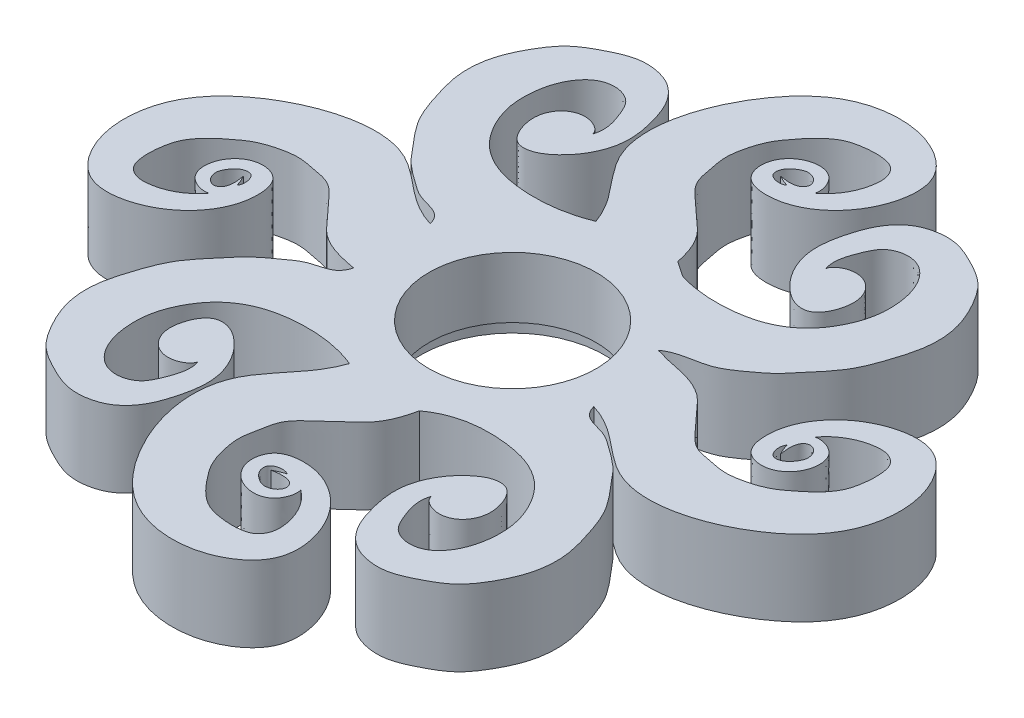
from build123d import *

# Parameters (mm, degrees)
BOSS_EXTRUDE2_DEPTH = 10
SKETCH2_R           = 13.166490973
BOSS_EXTRUDE4_DEPTH = 10
SKETCH4_R           = 10.996
CUT_EXTRUDE1_DEPTH  = 10
SKETCH5_R           = 12.126
CUT_EXTRUDE2_DEPTH  = 2


with BuildPart() as part:
    # Sketch1 → Boss-Extrude2 (new body)
    with BuildSketch(Plane(origin=(0, 0, 0), x_dir=(1, 0, 0), z_dir=(0, 1, 0))):
        with BuildLine():
            add(Edge.make_bspline(
                [(34.188363514, 44.956596514), (33.701598666, 43.048036253), (30.95739019, 43.115245722), (28.118998449, 40.970403917), (25.878188681, 39.331460779), (24.404677264, 37.426125449), (22.941084472, 35.794270593), (21.235407173, 33.479842018), (19.985078829, 30.008395243), (18.889058016, 26.247854831), (19.108830289, 22.745657785), (19.725757566, 20.92378151), (20.092106533, 20.092106533)],
                knots=[0, 0, 0, 0, 0.047266575, 0.084492057, 0.118112524, 0.141184856, 0.165634032, 0.192608699, 0.237940364, 0.289819658, 0.32418302, 0.354847276, 0.354847276, 0.354847276, 0.354847276], degree=3))
            Line((20.092106533, 20.092106533), (26.01328336, 26.01328336))
            add(Edge.make_bspline(
                [(26.01328336, 26.01328336), (26.052529787, 26.268426348), (26.278747771, 27.439968658), (27.14866517, 29.654095335), (29.108744684, 32.428855421), (31.966179785, 34.173665176), (33.996161891, 34.692283129), (34.836749566, 34.836749566)],
                knots=[0.460515809, 0.460515809, 0.460515809, 0.460515809, 0.478276136, 0.542635526, 0.623024021, 0.708168641, 0.766773984, 0.766773984, 0.766773984, 0.766773984], degree=3))
            Line((34.836749566, 34.836749566), (42.014455927, 42.014455927))
            add(Edge.make_bspline(
                [(34.188363514, 44.956596514), (34.412632763, 44.909046824), (35.135898032, 44.740206472), (36.778212553, 44.111022962), (39.947733796, 44.722787853), (41.031599473, 42.901571115), (42.014455927, 42.014455927)],
                knots=[0.810573593, 0.810573593, 0.810573593, 0.810573593, 0.822647339, 0.849801987, 0.902946428, 0.968114768, 0.968114768, 0.968114768, 0.968114768], degree=3))
        make_face()
        with BuildLine():
            Line((26.01328336, 26.01328336), (20.092106533, 20.092106533))
            add(Edge.make_bspline(
                [(20.092106533, 20.092106533), (20.391405304, 19.412646998), (21.173087456, 17.934573709), (22.855976348, 15.446940047), (25.899000157, 13.736428609), (29.019853456, 12.320498914), (31.692855633, 12.529433804), (34.075188007, 13.361697368), (36.025463952, 15.374095844), (37.304367596, 18.905964925), (38.234125799, 23.697087846), (36.050935714, 27.683689746), (33.885547102, 29.409321454), (32.695248955, 30.106562845), (30.959854801, 30.362175237), (29.737427553, 29.109049648), (29.167704554, 27.794524876), (28.848219551, 26.33981112), (29.051776005, 24.637379388), (29.977289897, 23.259457338), (31.684162076, 22.403328871), (33.422522957, 22.601417527), (34.534014203, 23.529934128), (34.637188493, 23.988642652), (34.646815974, 24.066379751)],
                knots=[0.354847276, 0.354847276, 0.354847276, 0.354847276, 0.379899275, 0.41085446, 0.455212464, 0.495953054, 0.524736546, 0.543496723, 0.580828475, 0.614309776, 0.670605327, 0.741152887, 0.752796809, 0.764260994, 0.788347673, 0.804360394, 0.819458631, 0.836969807, 0.854153952, 0.876412827, 0.889806592, 0.917326832, 0.931104592, 0.933826593, 0.933826593, 0.933826593, 0.933826593], degree=3))
            add(Edge.make_bspline(
                [(34.646815974, 24.066379751), (35.14201703, 22.640852122), (34.457931313, 20.557953149), (33.229845661, 17.848412965), (31.041923292, 16.974982467), (28.723356671, 17.471160138), (26.799485597, 19.52788522), (25.866296411, 22.561566295), (25.844067539, 24.913202835), (26.01328336, 26.01328336)],
                knots=[0, 0, 0, 0, 0.099619212, 0.145832416, 0.199041029, 0.246529323, 0.301572291, 0.383939961, 0.460515809, 0.460515809, 0.460515809, 0.460515809], degree=3))
        make_face()
        with BuildLine():
            add(Edge.make_bspline(
                [(79.907893467, 20.092106533), (79.608594696, 19.412646998), (78.826912544, 17.934573709), (77.144023652, 15.446940047), (74.100999843, 13.736428609), (70.980146544, 12.320498914), (68.307144367, 12.529433804), (65.924811993, 13.361697368), (63.974536048, 15.374095844), (62.695632404, 18.905964925), (61.765874201, 23.697087846), (63.949064286, 27.683689746), (66.114452898, 29.409321454), (67.304751045, 30.106562845), (69.040145199, 30.362175237), (70.262572447, 29.109049648), (70.832295446, 27.794524876), (71.151780449, 26.33981112), (70.948223995, 24.637379388), (70.022710103, 23.259457338), (68.315837924, 22.403328871), (66.577477043, 22.601417527), (65.465985797, 23.529934128), (65.362811507, 23.988642652), (65.353184026, 24.066379751)],
                knots=[0.354847276, 0.354847276, 0.354847276, 0.354847276, 0.379899275, 0.41085446, 0.455212464, 0.495953054, 0.524736546, 0.543496723, 0.580828475, 0.614309776, 0.670605327, 0.741152887, 0.752796809, 0.764260994, 0.788347673, 0.804360394, 0.819458631, 0.836969807, 0.854153952, 0.876412827, 0.889806592, 0.917326832, 0.931104592, 0.933826593, 0.933826593, 0.933826593, 0.933826593], degree=3))
            Line((79.907893467, 20.092106533), (73.986720472, 26.013279528))
            add(Edge.make_bspline(
                [(65.353184026, 24.066379751), (64.857982968, 22.640852128), (65.542068695, 20.557953125), (66.770154327, 17.848413003), (68.958076762, 16.974982309), (71.276643142, 17.471160691), (73.200515405, 19.527882257), (74.133699339, 22.561587505), (74.155943652, 24.91317945), (73.986720472, 26.013279528)],
                knots=[0, 0, 0, 0, 0.098273737, 0.143862778, 0.196352745, 0.243199654, 0.297499202, 0.3787544, 0.454296315, 0.454296315, 0.454296315, 0.454296315], degree=3))
        make_face()
        with BuildLine():
            Line((73.986720472, 26.013279528), (79.907893467, 20.092106533))
            add(Edge.make_bspline(
                [(65.811636486, 44.956596514), (66.298401334, 43.048036253), (69.04260981, 43.115245722), (71.881001551, 40.970403917), (74.121811319, 39.331460779), (75.595322736, 37.426125449), (77.058915528, 35.794270593), (78.764592827, 33.479842018), (80.014921171, 30.008395243), (81.110941984, 26.247854831), (80.891169711, 22.745657785), (80.274242434, 20.92378151), (79.907893467, 20.092106533)],
                knots=[0, 0, 0, 0, 0.047266575, 0.084492057, 0.118112524, 0.141184856, 0.165634032, 0.192608699, 0.237940364, 0.289819658, 0.32418302, 0.354847276, 0.354847276, 0.354847276, 0.354847276], degree=3))
            add(Edge.make_bspline(
                [(58.999511619, 43.561039694), (61.189200326, 45.409124558), (63.564168332, 45.615347007), (65.811636486, 44.956596514)],
                knots=[0.018252545, 0.018252545, 0.018252545, 0.018252545, 0.091662786, 0.091662786, 0.091662786, 0.091662786], degree=3))
            add(Edge.make_bspline(
                [(57.985544073, 42.014455927), (58.366591704, 42.436627849), (58.726230487, 42.929989082), (58.999511619, 43.561039694)],
                knots=[0.968114768, 0.968114768, 0.968114768, 0.968114768, 0.996106896, 0.996106896, 0.996106896, 0.996106896], degree=3))
            Line((57.985544073, 42.014455927), (65.166884419, 34.833115581))
            add(Edge.make_bspline(
                [(73.986720472, 26.013279528), (73.947473207, 26.268421402), (73.721246456, 27.439985024), (72.851273596, 29.654276415), (70.891559836, 32.427954896), (68.033533359, 34.176288831), (66.007033807, 34.687361047), (65.166884419, 34.833115581)],
                knots=[0.454296315, 0.454296315, 0.454296315, 0.454296315, 0.471816454, 0.535306594, 0.614609348, 0.698603989, 0.756359253, 0.756359253, 0.756359253, 0.756359253], degree=3))
        make_face()
        with BuildLine():
            add(Edge.make_bspline(
                [(20.092106533, 79.907893467), (20.391405304, 80.587353002), (21.173087456, 82.065426291), (22.855976348, 84.553059953), (25.899000157, 86.263571391), (29.019853456, 87.679501086), (31.692855633, 87.470566196), (34.075188007, 86.638302632), (36.025463952, 84.625904156), (37.304367596, 81.094035075), (38.234125799, 76.302912154), (36.050935714, 72.316310254), (33.885547102, 70.590678546), (32.695248955, 69.893437155), (30.959854801, 69.637824763), (29.737427553, 70.890950352), (29.167704554, 72.205475124), (28.848219551, 73.66018888), (29.051776005, 75.362620612), (29.977289897, 76.740542662), (31.684162076, 77.596671129), (33.422522957, 77.398582473), (34.534014203, 76.470065872), (34.637188493, 76.011357348), (34.646815974, 75.933620249)],
                knots=[0.354847276, 0.354847276, 0.354847276, 0.354847276, 0.379899275, 0.41085446, 0.455212464, 0.495953054, 0.524736546, 0.543496723, 0.580828475, 0.614309776, 0.670605327, 0.741152887, 0.752796809, 0.764260994, 0.788347673, 0.804360394, 0.819458631, 0.836969807, 0.854153952, 0.876412827, 0.889806592, 0.917326832, 0.931104592, 0.933826593, 0.933826593, 0.933826593, 0.933826593], degree=3))
            Line((20.092106533, 79.907893467), (26.01328336, 73.98671664))
            add(Edge.make_bspline(
                [(34.646815974, 75.933620249), (35.14201703, 77.359147878), (34.457931313, 79.442046851), (33.229845661, 82.151587035), (31.041923292, 83.025017533), (28.723356671, 82.528839862), (26.799485597, 80.47211478), (25.866296411, 77.438433705), (25.844067539, 75.086797165), (26.01328336, 73.98671664)],
                knots=[0, 0, 0, 0, 0.099619212, 0.145832416, 0.199041029, 0.246529323, 0.301572291, 0.383939961, 0.460515809, 0.460515809, 0.460515809, 0.460515809], degree=3))
        make_face()
        with BuildLine():
            Line((26.01328336, 73.98671664), (20.092106533, 79.907893467))
            add(Edge.make_bspline(
                [(34.188363514, 55.043403486), (33.701598666, 56.951963747), (30.95739019, 56.884754278), (28.118998449, 59.029596083), (25.878188681, 60.668539221), (24.404677264, 62.573874551), (22.941084472, 64.205729407), (21.235407173, 66.520157982), (19.985078829, 69.991604757), (18.889058016, 73.752145169), (19.108830289, 77.254342215), (19.725757566, 79.07621849), (20.092106533, 79.907893467)],
                knots=[0, 0, 0, 0, 0.047266575, 0.084492057, 0.118112524, 0.141184856, 0.165634032, 0.192608699, 0.237940364, 0.289819658, 0.32418302, 0.354847276, 0.354847276, 0.354847276, 0.354847276], degree=3))
            add(Edge.make_bspline(
                [(41.228865774, 56.63831337), (38.976587284, 54.606309361), (36.514201974, 54.361682043), (34.188363514, 55.043403486)],
                knots=[0.015692694, 0.015692694, 0.015692694, 0.015692694, 0.091662786, 0.091662786, 0.091662786, 0.091662786], degree=3))
            ThreePointArc((41.228865774, 56.63831337), (41.538778856, 57.029063717), (41.866085127, 57.405364869))
            ThreePointArc((41.866085127, 57.405364869), (42.041771895, 57.593853135), (42.221825407, 57.778174593))
            Line((42.221825407, 57.778174593), (34.836749566, 65.163250434))
            add(Edge.make_bspline(
                [(26.01328336, 73.98671664), (26.052529787, 73.731573652), (26.278747771, 72.560031342), (27.14866517, 70.345904665), (29.108744684, 67.571144579), (31.966179785, 65.826334824), (33.996161891, 65.307716871), (34.836749566, 65.163250434)],
                knots=[0.460515809, 0.460515809, 0.460515809, 0.460515809, 0.478276136, 0.542635526, 0.623024021, 0.708168641, 0.766773984, 0.766773984, 0.766773984, 0.766773984], degree=3))
        make_face()
        with BuildLine():
            add(Edge.make_bspline(
                [(16.160494625, 43.96111936), (14.986864586, 42.379235873), (12.592744084, 41.012743048), (9.465709528, 40.96551986), (8.026422717, 41.910411497), (7.550806508, 43.748330363), (7.647195031, 45.75277335), (8.069282603, 47.971716016), (9.432801166, 49.882198225), (11.219922046, 51.401479152), (13.316786407, 52.95305245), (15.672674157, 53.673961961), (18.087107893, 54.068440293), (20.330842421, 53.550169721), (22.892165795, 53.186443439), (24.769702556, 51.12420354), (26.684889568, 49.06748532), (28.919014682, 46.346067881), (31.874813568, 45.376238518), (33.79367813, 45.040277927), (34.188363514, 44.956596514)],
                knots=[0, 0, 0, 0, 0.103133744, 0.133672356, 0.160054586, 0.186139677, 0.228666647, 0.265873413, 0.302525941, 0.34902888, 0.389122541, 0.4381572, 0.476950983, 0.515572502, 0.558652472, 0.608310362, 0.655131306, 0.708599715, 0.789325333, 0.810573593, 0.810573593, 0.810573593, 0.810573593], degree=3))
            add(Edge.make_bspline(
                [(34.188363514, 44.956596514), (34.412632763, 44.909046824), (35.135898032, 44.740206472), (36.778212553, 44.111022962), (39.947733796, 44.722787853), (41.031599473, 42.901571115), (42.014455927, 42.014455927)],
                knots=[0.810573593, 0.810573593, 0.810573593, 0.810573593, 0.822647339, 0.849801987, 0.902946428, 0.968114768, 0.968114768, 0.968114768, 0.968114768], degree=3))
            Line((42.014455927, 42.014455927), (42.221825407, 42.221825407))
            ThreePointArc((42.221825407, 42.221825407), (42.041771895, 42.406146865), (41.866085127, 42.594635131))
            ThreePointArc((41.866085127, 42.594635131), (39.011305998, 49.501397827), (41.228865774, 56.63831337))
            add(Edge.make_bspline(
                [(41.228865774, 56.63831337), (38.976587284, 54.606309361), (36.514201974, 54.361682043), (34.188363514, 55.043403486)],
                knots=[0.015692694, 0.015692694, 0.015692694, 0.015692694, 0.091662786, 0.091662786, 0.091662786, 0.091662786], degree=3))
            add(Edge.make_bspline(
                [(34.188363514, 55.043403486), (32.988757012, 55.395017534), (29.597040142, 57.138700626), (22.985132601, 64.13491873), (10.103143612, 60.465996346), (1.846885834, 51.957990237), (1.634403442, 42.951143194), (6.767093741, 36.729262075), (13.487499365, 37.728070412), (18.147246483, 41.515948147), (19.922544307, 46.038195425), (19.184657897, 50.305501367), (15.417936423, 51.104416641), (12.630967645, 48.726147208), (12.560989705, 44.684698735), (15.201485328, 43.712661691), (16.160494625, 43.96111936)],
                knots=[0.091662786, 0.091662786, 0.091662786, 0.091662786, 0.130846168, 0.205907606, 0.373668348, 0.458524244, 0.563429024, 0.616001906, 0.684326796, 0.743988773, 0.794856123, 0.830050979, 0.857943881, 0.895209986, 0.928487465, 0.961873919, 0.961873919, 0.961873919, 0.961873919], degree=3))
        make_face()
        with BuildLine():
            add(Edge.make_bspline(
                [(16.480040826, 48.178626232), (16.592128106, 47.528012831), (16.737195952, 46.59846685), (16.301672382, 45.417068995), (15.580197675, 45.116345164), (14.941408745, 45.337928813), (14.493316803, 45.783133929), (14.277188548, 46.356103882), (14.1963921, 46.948802008), (14.438639408, 47.616279928), (14.910750096, 48.31149619), (15.627269466, 48.946980069), (17.316467934, 49.150329476), (17.504986229, 47.195958075), (17.092499363, 46.720147552)],
                knots=[0, 0, 0, 0, 0.16636553, 0.241726144, 0.29922749, 0.344909014, 0.407108122, 0.454045417, 0.499648781, 0.556760972, 0.630203201, 0.713356713, 0.798617516, 1, 1, 1, 1], degree=3))
            add(Edge.make_bspline(
                [(17.092499363, 46.720147552), (16.962306122, 47.149811619), (16.76240491, 47.634622725), (16.480040826, 48.178626232)],
                knots=[0.992293125, 0.992293125, 0.992293125, 0.992293125, 1, 1, 1, 1], degree=3))
        make_face(mode=Mode.SUBTRACT)
        with BuildLine():
            add(Edge.make_bspline(
                [(63.619252851, 55.615166428), (65.217749299, 56.807977108), (68.566089002, 56.61671767), (71.887711223, 59.017839913), (74.120685104, 60.670512487), (75.595591616, 62.57340344), (77.058834536, 64.205871316), (78.764632843, 66.520087869), (80.014906002, 69.991631335), (81.110944653, 73.752140493), (80.891169349, 77.25434267), (80.27424218, 79.076218783), (79.907893422, 79.907893422)],
                knots=[0, 0, 0, 0, 0.064389944, 0.100946377, 0.133962587, 0.156620243, 0.180629997, 0.207119851, 0.251636775, 0.302583648, 0.336329402, 0.366442526, 0.366442526, 0.366442526, 0.366442526], degree=3))
            Line((79.907893422, 79.907893422), (73.986716963, 73.986716963))
            add(Edge.make_bspline(
                [(73.986716963, 73.986716963), (73.947470464, 73.731574111), (73.721251671, 72.56002965), (72.85132918, 70.34588619), (70.891283414, 67.571236458), (68.033804779, 65.826069284), (66.004157648, 65.308221706), (65.163622957, 65.163622957)],
                knots=[0.479848557, 0.479848557, 0.479848557, 0.479848557, 0.498354438, 0.565415671, 0.649178921, 0.737897959, 0.798956978, 0.798956978, 0.798956978, 0.798956978], degree=3))
            Line((65.163622957, 65.163622957), (57.985544073, 57.985544073))
            add(Edge.make_bspline(
                [(63.619252851, 55.615166428), (62.609079309, 55.770749147), (60.04783606, 55.284656108), (58.968400527, 57.098428885), (57.985544073, 57.985544073)],
                knots=[0.850285574, 0.850285574, 0.850285574, 0.850285574, 0.902946428, 0.968114768, 0.968114768, 0.968114768, 0.968114768], degree=3))
        make_face()
        with BuildLine():
            Line((73.986716963, 73.986716963), (79.907893422, 79.907893422))
            add(Edge.make_bspline(
                [(79.907893422, 79.907893422), (79.608594677, 80.587353011), (78.826912774, 82.065425919), (77.144023601, 84.553060043), (74.100999858, 86.263571365), (70.980146542, 87.67950109), (68.307144368, 87.470566196), (65.924811993, 86.638302632), (63.974536048, 84.625904156), (62.695632404, 81.094035075), (61.765874201, 76.302912154), (63.949064286, 72.316310254), (66.114452898, 70.590678546), (67.304751045, 69.893437155), (69.040145199, 69.637824763), (70.262572447, 70.890950352), (70.832295446, 72.205475124), (71.151780449, 73.66018888), (70.948223995, 75.362620612), (70.022710103, 76.740542662), (68.315837924, 77.596671129), (66.577477043, 77.398582473), (65.465985797, 76.470065872), (65.362811507, 76.011357348), (65.353184026, 75.933620249)],
                knots=[0.366442526, 0.366442526, 0.366442526, 0.366442526, 0.391044274, 0.421443106, 0.465003868, 0.505012233, 0.533278402, 0.551701404, 0.588362197, 0.621241742, 0.6765255, 0.745805117, 0.757239764, 0.768497904, 0.792151676, 0.807876602, 0.822703481, 0.83989993, 0.856775226, 0.878634045, 0.891787086, 0.918812708, 0.932342842, 0.93501592, 0.93501592, 0.93501592, 0.93501592], degree=3))
            add(Edge.make_bspline(
                [(65.353184026, 75.933620249), (64.857982969, 77.359147877), (65.542068688, 79.442046853), (66.770154338, 82.151587031), (68.958076713, 83.025017549), (71.276643312, 82.528839806), (73.200514495, 80.472115082), (74.133703218, 77.438431519), (74.155933495, 75.086799504), (73.986716963, 73.986716963)],
                knots=[0, 0, 0, 0, 0.103801283, 0.151954543, 0.207396883, 0.256878763, 0.314232465, 0.400057977, 0.479848557, 0.479848557, 0.479848557, 0.479848557], degree=3))
        make_face()
        with BuildLine():
            add(Edge.make_bspline(
                [(58.999511619, 43.561039694), (61.189200326, 45.409124558), (63.564168332, 45.615347007), (65.811636486, 44.956596514)],
                knots=[0.018252545, 0.018252545, 0.018252545, 0.018252545, 0.091662786, 0.091662786, 0.091662786, 0.091662786], degree=3))
            add(Edge.make_bspline(
                [(65.811636486, 44.956596514), (67.011242988, 44.604982466), (70.402959858, 42.861299374), (77.014867399, 35.86508127), (89.896856388, 39.534003654), (98.153114166, 48.042009763), (98.365596558, 57.048856806), (93.232906259, 63.270737925), (86.512500635, 62.271929588), (81.852753517, 58.484051853), (80.077455693, 53.961804575), (80.815342103, 49.694498633), (84.582063577, 48.895583359), (87.369032355, 51.273852792), (87.439010295, 55.315301265), (84.798514672, 56.287338309), (83.839505375, 56.03888064)],
                knots=[0.091662786, 0.091662786, 0.091662786, 0.091662786, 0.130846168, 0.205907606, 0.373668348, 0.458524244, 0.563429024, 0.616001906, 0.684326796, 0.743988773, 0.794856123, 0.830050979, 0.857943881, 0.895209986, 0.928487465, 0.961873919, 0.961873919, 0.961873919, 0.961873919], degree=3))
            add(Edge.make_bspline(
                [(83.839505375, 56.03888064), (85.013135414, 57.620764127), (87.407255916, 58.987256952), (90.534290472, 59.03448014), (91.973577283, 58.089588503), (92.449193492, 56.251669637), (92.352804969, 54.24722665), (91.930717397, 52.028283984), (90.567198834, 50.117801775), (88.780077954, 48.598520848), (86.683213593, 47.04694755), (84.327325843, 46.326038039), (81.912892107, 45.931559707), (79.669157579, 46.449830279), (77.107834205, 46.813556561), (75.230297444, 48.87579646), (73.315110432, 50.93251468), (71.080985318, 53.653932119), (67.895599183, 54.699091525), (65.241878897, 55.115064238), (64.166652748, 55.526991767), (63.647047863, 55.610785299)],
                knots=[0, 0, 0, 0, 0.103133744, 0.133672356, 0.160054586, 0.186139677, 0.228666647, 0.265873413, 0.302525941, 0.34902888, 0.389122541, 0.4381572, 0.476950983, 0.515572502, 0.558652472, 0.608310362, 0.655131306, 0.708599715, 0.789325333, 0.822647339, 0.849801987, 0.849801987, 0.849801987, 0.849801987], degree=3))
            add(Edge.make_bspline(
                [(63.647047863, 55.610785299), (63.637794424, 55.612277545), (63.628529309, 55.613737706), (63.619252851, 55.615166428)],
                knots=[0.849801987, 0.849801987, 0.849801987, 0.849801987, 0.850285574, 0.850285574, 0.850285574, 0.850285574], degree=3))
            add(Edge.make_bspline(
                [(63.619252851, 55.615166428), (62.609079309, 55.770749147), (60.04783606, 55.284656108), (58.968400527, 57.098428885), (57.985544073, 57.985544073)],
                knots=[0.850285574, 0.850285574, 0.850285574, 0.850285574, 0.902946428, 0.968114768, 0.968114768, 0.968114768, 0.968114768], degree=3))
            add(Edge.make_bspline(
                [(57.985544073, 57.985544073), (58.419587249, 57.5046571), (58.825852446, 56.931402004), (59.108348304, 56.167494723)],
                knots=[0.968114768, 0.968114768, 0.968114768, 0.968114768, 1, 1, 1, 1], degree=3))
            ThreePointArc((59.108348304, 56.167494723), (60.516459275, 53.225536285), (61, 50))
            ThreePointArc((61, 50), (60.516459275, 46.774463715), (59.108348304, 43.832505277))
            add(Edge.make_bspline(
                [(58.999511619, 43.561039694), (59.037519157, 43.648805286), (59.073856294, 43.739234181), (59.108348304, 43.832505277)],
                knots=[0.996106896, 0.996106896, 0.996106896, 0.996106896, 1, 1, 1, 1], degree=3))
        make_face()
        with BuildLine():
            add(Edge.make_bspline(
                [(83.519959174, 51.821373768), (83.407871894, 52.471987169), (83.262804048, 53.40153315), (83.698327618, 54.582931005), (84.419802325, 54.883654836), (85.058591255, 54.662071187), (85.506683197, 54.216866071), (85.722811452, 53.643896118), (85.8036079, 53.051197992), (85.561360592, 52.383720072), (85.089249904, 51.68850381), (84.372730534, 51.053019931), (82.683532066, 50.849670524), (82.495013771, 52.804041925), (82.907500637, 53.279852448)],
                knots=[0, 0, 0, 0, 0.16636553, 0.241726144, 0.29922749, 0.344909014, 0.407108122, 0.454045417, 0.499648781, 0.556760972, 0.630203201, 0.713356713, 0.798617516, 1, 1, 1, 1], degree=3))
            add(Edge.make_bspline(
                [(82.907500637, 53.279852448), (83.037693878, 52.850188381), (83.23759509, 52.365377275), (83.519959174, 51.821373768)],
                knots=[0.992293125, 0.992293125, 0.992293125, 0.992293125, 1, 1, 1, 1], degree=3))
        make_face(mode=Mode.SUBTRACT)
        with BuildLine():
            Line((42.014455927, 42.014455927), (34.836749566, 34.836749566))
            add(Edge.make_bspline(
                [(34.836749566, 34.836749566), (35.127532864, 34.886724635), (38.490614827, 35.369450815), (41.950755989, 34.971413705), (44.827882558, 33.782431504)],
                knots=[0.766773984, 0.766773984, 0.766773984, 0.766773984, 0.787047246, 1, 1, 1, 1], degree=3))
            add(Edge.make_bspline(
                [(43.561039694, 41.000488381), (45.520791717, 38.678491725), (45.634273864, 36.148148995), (44.827882558, 33.782431504)],
                knots=[0.018252545, 0.018252545, 0.018252545, 0.018252545, 0.096098466, 0.096098466, 0.096098466, 0.096098466], degree=3))
            add(Edge.make_bspline(
                [(42.014455927, 42.014455927), (42.436627849, 41.633408296), (42.929989082, 41.273769513), (43.561039694, 41.000488381)],
                knots=[0.968114768, 0.968114768, 0.968114768, 0.968114768, 0.996106896, 0.996106896, 0.996106896, 0.996106896], degree=3))
        make_face()
        with BuildLine():
            add(Edge.make_bspline(
                [(65.166884419, 34.833115581), (64.875106499, 34.883735096), (61.309745267, 35.407065501), (57.596457215, 35.058299276), (54.806676969, 32.993134393)],
                knots=[0.756359253, 0.756359253, 0.756359253, 0.756359253, 0.776417246, 1, 1, 1, 1], degree=3))
            Line((65.166884419, 34.833115581), (57.985544073, 42.014455927))
            add(Edge.make_bspline(
                [(54.806676969, 32.993134393), (54.936903945, 33.621537936), (55.115064238, 34.758121103), (55.888977038, 36.778212553), (55.277212147, 39.947733796), (57.098428885, 41.031599473), (57.985544073, 42.014455927)],
                knots=[0.789325333, 0.789325333, 0.789325333, 0.789325333, 0.822647339, 0.849801987, 0.902946428, 0.968114768, 0.968114768, 0.968114768, 0.968114768], degree=3))
        make_face()
        with BuildLine():
            add(Edge.make_bspline(
                [(34.836749566, 65.163250434), (35.127532864, 65.113275365), (38.490614827, 64.630549185), (41.950755989, 65.028586295), (44.827882558, 66.217568496)],
                knots=[0.766773984, 0.766773984, 0.766773984, 0.766773984, 0.787047246, 1, 1, 1, 1], degree=3))
            Line((34.836749566, 65.163250434), (42.221825407, 57.778174593))
            ThreePointArc((42.221825407, 57.778174593), (42.406146865, 57.958228105), (42.594635131, 58.133914873))
            ThreePointArc((42.594635131, 58.133914873), (42.970936283, 58.461221144), (43.36168663, 58.771134226))
            add(Edge.make_bspline(
                [(43.36168663, 58.771134226), (45.512333639, 61.154916923), (45.660790878, 63.7740578), (44.827882558, 66.217568496)],
                knots=[0.015692694, 0.015692694, 0.015692694, 0.015692694, 0.096098466, 0.096098466, 0.096098466, 0.096098466], degree=3))
        make_face()
        with BuildLine():
            add(Edge.make_bspline(
                [(42.271128523, 57.728871477), (41.929759507, 57.31922896), (41.581893616, 56.956814831), (41.228865774, 56.63831337)],
                knots=[0.003784949, 0.003784949, 0.003784949, 0.003784949, 0.015692694, 0.015692694, 0.015692694, 0.015692694], degree=3))
            ThreePointArc((41.228865774, 56.63831337), (39.011305998, 49.501397827), (41.866085127, 42.594635131))
            add(Edge.make_bspline(
                [(41.866085127, 42.594635131), (42.005942181, 42.48748457), (42.140921153, 42.379634744), (42.271128523, 42.271128523)],
                knots=[0, 0, 0, 0, 0.003784949, 0.003784949, 0.003784949, 0.003784949], degree=3))
            Line((42.271128523, 42.271128523), (50, 50))
            Line((50, 50), (42.271128523, 57.728871477))
        make_face()
        with BuildLine():
            add(Edge.make_bspline(
                [(43.561039694, 41.000488381), (45.520791717, 38.678491725), (45.634273864, 36.148148995), (44.827882558, 33.782431504)],
                knots=[0.018252545, 0.018252545, 0.018252545, 0.018252545, 0.096098466, 0.096098466, 0.096098466, 0.096098466], degree=3))
            add(Edge.make_bspline(
                [(44.827882558, 33.782431504), (44.467937629, 32.726457801), (42.751255499, 29.493041108), (35.86508127, 22.985132601), (39.534003654, 10.103143612), (48.042009763, 1.846885834), (57.048856806, 1.634403442), (63.270737925, 6.767093741), (62.271929588, 13.487499365), (58.484051853, 18.147246483), (53.961804575, 19.922544307), (49.694498633, 19.184657897), (48.895583359, 15.417936423), (51.273852792, 12.630967645), (55.315301265, 12.560989705), (56.287338309, 15.201485328), (56.03888064, 16.160494625)],
                knots=[0.096098466, 0.096098466, 0.096098466, 0.096098466, 0.130846168, 0.205907606, 0.373668348, 0.458524244, 0.563429024, 0.616001906, 0.684326796, 0.743988773, 0.794856123, 0.830050979, 0.857943881, 0.895209986, 0.928487465, 0.961873919, 0.961873919, 0.961873919, 0.961873919], degree=3))
            add(Edge.make_bspline(
                [(56.03888064, 16.160494625), (57.620764127, 14.986864586), (58.987256952, 12.592744084), (59.03448014, 9.465709528), (58.089588503, 8.026422717), (56.251669637, 7.550806508), (54.24722665, 7.647195031), (52.028283984, 8.069282603), (50.117801775, 9.432801166), (48.598520848, 11.219922046), (47.04694755, 13.316786407), (46.326038039, 15.672674157), (45.931559707, 18.087107893), (46.449830279, 20.330842421), (46.813556561, 22.892165795), (48.87579646, 24.769702556), (50.93251468, 26.684889568), (53.653932119, 28.919014682), (54.491190178, 31.470769179), (54.806676969, 32.993134393)],
                knots=[0, 0, 0, 0, 0.103133744, 0.133672356, 0.160054586, 0.186139677, 0.228666647, 0.265873413, 0.302525941, 0.34902888, 0.389122541, 0.4381572, 0.476950983, 0.515572502, 0.558652472, 0.608310362, 0.655131306, 0.708599715, 0.789325333, 0.789325333, 0.789325333, 0.789325333], degree=3))
            add(Edge.make_bspline(
                [(54.806676969, 32.993134393), (54.936903945, 33.621537936), (55.115064238, 34.758121103), (55.888977038, 36.778212553), (55.277212147, 39.947733796), (57.098428885, 41.031599473), (57.985544073, 42.014455927)],
                knots=[0.789325333, 0.789325333, 0.789325333, 0.789325333, 0.822647339, 0.849801987, 0.902946428, 0.968114768, 0.968114768, 0.968114768, 0.968114768], degree=3))
            Line((57.985544073, 42.014455927), (57.778174593, 42.221825407))
            ThreePointArc((57.778174593, 42.221825407), (57.593853135, 42.041771895), (57.405364869, 41.866085127))
            ThreePointArc((57.405364869, 41.866085127), (50.787693311, 39.028239009), (43.832505277, 40.891651696))
            add(Edge.make_bspline(
                [(43.561039694, 41.000488381), (43.648805286, 40.962480843), (43.739234181, 40.926143706), (43.832505277, 40.891651696)],
                knots=[0.996106896, 0.996106896, 0.996106896, 0.996106896, 1, 1, 1, 1], degree=3))
        make_face()
        with BuildLine():
            add(Edge.make_bspline(
                [(51.821373768, 16.480040826), (52.471987169, 16.592128106), (53.40153315, 16.737195952), (54.582931005, 16.301672382), (54.883654836, 15.580197675), (54.662071187, 14.941408745), (54.216866071, 14.493316803), (53.643896118, 14.277188548), (53.051197992, 14.1963921), (52.383720072, 14.438639408), (51.68850381, 14.910750096), (51.053019931, 15.627269466), (50.849670524, 17.316467934), (52.804041925, 17.504986229), (53.279852448, 17.092499363)],
                knots=[0, 0, 0, 0, 0.16636553, 0.241726144, 0.29922749, 0.344909014, 0.407108122, 0.454045417, 0.499648781, 0.556760972, 0.630203201, 0.713356713, 0.798617516, 1, 1, 1, 1], degree=3))
            add(Edge.make_bspline(
                [(53.279852448, 17.092499363), (52.850188381, 16.962306122), (52.365377275, 16.76240491), (51.821373768, 16.480040826)],
                knots=[0.992293125, 0.992293125, 0.992293125, 0.992293125, 1, 1, 1, 1], degree=3))
        make_face(mode=Mode.SUBTRACT)
        with BuildLine():
            Line((57.985544073, 57.985544073), (65.163622957, 65.163622957))
            add(Edge.make_bspline(
                [(65.163622957, 65.163622957), (64.872735525, 65.11358105), (62.090237287, 64.713260631), (59.239111577, 64.908530138), (56.838699435, 65.649514164)],
                knots=[0.798956978, 0.798956978, 0.798956978, 0.798956978, 0.820087933, 1, 1, 1, 1], degree=3))
            add(Edge.make_bspline(
                [(56.838699435, 65.649514164), (54.806676969, 67.006865607)],
                knots=[0, 0, 1, 1], degree=1))
            add(Edge.make_bspline(
                [(54.806676969, 67.006865607), (54.936903945, 66.378462064), (55.115064238, 65.241878897), (55.888977038, 63.221787447), (55.277212147, 60.052266204), (57.098428885, 58.968400527), (57.985544073, 57.985544073)],
                knots=[0.789325333, 0.789325333, 0.789325333, 0.789325333, 0.822647339, 0.849801987, 0.902946428, 0.968114768, 0.968114768, 0.968114768, 0.968114768], degree=3))
        make_face()
        with BuildLine():
            add(Edge.make_bspline(
                [(57.985544073, 57.985544073), (57.5046571, 58.419587249), (56.931402004, 58.825852446), (56.167494723, 59.108348304)],
                knots=[0.968114768, 0.968114768, 0.968114768, 0.968114768, 1, 1, 1, 1], degree=3))
            add(Edge.make_bspline(
                [(54.806676969, 67.006865607), (54.936903945, 66.378462064), (55.115064238, 65.241878897), (55.888977038, 63.221787447), (55.277212147, 60.052266204), (57.098428885, 58.968400527), (57.985544073, 57.985544073)],
                knots=[0.789325333, 0.789325333, 0.789325333, 0.789325333, 0.822647339, 0.849801987, 0.902946428, 0.968114768, 0.968114768, 0.968114768, 0.968114768], degree=3))
            add(Edge.make_bspline(
                [(56.03888064, 83.839505375), (57.620764127, 85.013135414), (58.987256952, 87.407255916), (59.03448014, 90.534290472), (58.089588503, 91.973577283), (56.251669637, 92.449193492), (54.24722665, 92.352804969), (52.028283984, 91.930717397), (50.117801775, 90.567198834), (48.598520848, 88.780077954), (47.04694755, 86.683213593), (46.326038039, 84.327325843), (45.931559707, 81.912892107), (46.449830279, 79.669157579), (46.813556561, 77.107834205), (48.87579646, 75.230297444), (50.93251468, 73.315110432), (53.653932119, 71.080985318), (54.491190178, 68.529230821), (54.806676969, 67.006865607)],
                knots=[0, 0, 0, 0, 0.103133744, 0.133672356, 0.160054586, 0.186139677, 0.228666647, 0.265873413, 0.302525941, 0.34902888, 0.389122541, 0.4381572, 0.476950983, 0.515572502, 0.558652472, 0.608310362, 0.655131306, 0.708599715, 0.789325333, 0.789325333, 0.789325333, 0.789325333], degree=3))
            add(Edge.make_bspline(
                [(44.827882558, 66.217568496), (44.467937629, 67.273542199), (42.751255499, 70.506958892), (35.86508127, 77.014867399), (39.534003654, 89.896856388), (48.042009763, 98.153114166), (57.048856806, 98.365596558), (63.270737925, 93.232906259), (62.271929588, 86.512500635), (58.484051853, 81.852753517), (53.961804575, 80.077455693), (49.694498633, 80.815342103), (48.895583359, 84.582063577), (51.273852792, 87.369032355), (55.315301265, 87.439010295), (56.287338309, 84.798514672), (56.03888064, 83.839505375)],
                knots=[0.096098466, 0.096098466, 0.096098466, 0.096098466, 0.130846168, 0.205907606, 0.373668348, 0.458524244, 0.563429024, 0.616001906, 0.684326796, 0.743988773, 0.794856123, 0.830050979, 0.857943881, 0.895209986, 0.928487465, 0.961873919, 0.961873919, 0.961873919, 0.961873919], degree=3))
            add(Edge.make_bspline(
                [(43.36168663, 58.771134226), (45.512333639, 61.154916923), (45.660790878, 63.7740578), (44.827882558, 66.217568496)],
                knots=[0.015692694, 0.015692694, 0.015692694, 0.015692694, 0.096098466, 0.096098466, 0.096098466, 0.096098466], degree=3))
            ThreePointArc((43.36168663, 58.771134226), (49.710438464, 60.996188163), (56.167494723, 59.108348304))
        make_face()
        with BuildLine():
            add(Edge.make_bspline(
                [(53.279852448, 82.907500637), (52.850188381, 83.037693878), (52.365377275, 83.23759509), (51.821373768, 83.519959174)],
                knots=[0.992293125, 0.992293125, 0.992293125, 0.992293125, 1, 1, 1, 1], degree=3))
            add(Edge.make_bspline(
                [(51.821373768, 83.519959174), (52.471987169, 83.407871894), (53.40153315, 83.262804048), (54.582931005, 83.698327618), (54.883654836, 84.419802325), (54.662071187, 85.058591255), (54.216866071, 85.506683197), (53.643896118, 85.722811452), (53.051197992, 85.8036079), (52.383720072, 85.561360592), (51.68850381, 85.089249904), (51.053019931, 84.372730534), (50.849670524, 82.683532066), (52.804041925, 82.495013771), (53.279852448, 82.907500637)],
                knots=[0, 0, 0, 0, 0.16636553, 0.241726144, 0.29922749, 0.344909014, 0.407108122, 0.454045417, 0.499648781, 0.556760972, 0.630203201, 0.713356713, 0.798617516, 1, 1, 1, 1], degree=3))
        make_face(mode=Mode.SUBTRACT)
        with BuildLine():
            ThreePointArc((58.771134226, 43.36168663), (58.942840233, 43.594876382), (59.108348304, 43.832505277))
            ThreePointArc((59.108348304, 43.832505277), (60.516459275, 46.774463715), (61, 50))
            ThreePointArc((61, 50), (60.516459275, 53.225536285), (59.108348304, 56.167494723))
            ThreePointArc((59.108348304, 56.167494723), (58.481582182, 57.004481687), (57.778174593, 57.778174593))
            Line((57.778174593, 57.778174593), (50, 50))
            Line((50, 50), (57.728871477, 42.271128523))
            add(Edge.make_bspline(
                [(57.728871477, 42.271128523), (58.070240493, 42.68077104), (58.418106384, 43.043185169), (58.771134226, 43.36168663)],
                knots=[0.003784949, 0.003784949, 0.003784949, 0.003784949, 0.015692694, 0.015692694, 0.015692694, 0.015692694], degree=3))
        make_face()
        with BuildLine():
            add(Edge.make_bspline(
                [(42.271128523, 57.728871477), (42.68077104, 58.070240493), (43.043185169, 58.418106384), (43.36168663, 58.771134226)],
                knots=[0.003784949, 0.003784949, 0.003784949, 0.003784949, 0.015692694, 0.015692694, 0.015692694, 0.015692694], degree=3))
            Line((42.271128523, 57.728871477), (50, 50))
            Line((50, 50), (57.778174593, 57.778174593))
            ThreePointArc((57.778174593, 57.778174593), (57.004481687, 58.481582182), (56.167494723, 59.108348304))
            ThreePointArc((56.167494723, 59.108348304), (49.710438464, 60.996188163), (43.36168663, 58.771134226))
        make_face()
        with BuildLine():
            Line((50, 50), (42.271128523, 42.271128523))
            add(Edge.make_bspline(
                [(42.271128523, 42.271128523), (42.68077104, 41.929759507), (43.043185169, 41.581893616), (43.36168663, 41.228865774)],
                knots=[0.003784949, 0.003784949, 0.003784949, 0.003784949, 0.015692694, 0.015692694, 0.015692694, 0.015692694], degree=3))
            ThreePointArc((43.36168663, 41.228865774), (43.594876382, 41.057159767), (43.832505277, 40.891651696))
            ThreePointArc((43.832505277, 40.891651696), (50.787693311, 39.028239009), (57.405364869, 41.866085127))
            add(Edge.make_bspline(
                [(57.405364869, 41.866085127), (57.51251543, 42.005942181), (57.620365256, 42.140921153), (57.728871477, 42.271128523)],
                knots=[0, 0, 0, 0, 0.003784949, 0.003784949, 0.003784949, 0.003784949], degree=3))
            Line((57.728871477, 42.271128523), (50, 50))
        make_face()
    extrude(amount=BOSS_EXTRUDE2_DEPTH)

    # Sketch2 → Boss-Extrude4 (add)
    with BuildSketch(Plane(origin=(0, 0, 0), x_dir=(1, 0, 0), z_dir=(0, 1, 0))):
        with Locations((51.336199781, 49.053362674)):
            Circle(SKETCH2_R)
    extrude(amount=BOSS_EXTRUDE4_DEPTH)

    # Sketch4 → Cut-Extrude1 (cut)
    with BuildSketch(Plane(origin=(0, 10, 0), x_dir=(1, 0, 0), z_dir=(0, 1, 0))):
        with Locations((50.657002671, 49.42321974)):
            Circle(SKETCH4_R)
    extrude(amount=-CUT_EXTRUDE1_DEPTH, mode=Mode.SUBTRACT)

    # Sketch5 → Cut-Extrude2 (cut)
    with BuildSketch(Plane(origin=(0, 0, 0), x_dir=(1, 0, 0), z_dir=(0, 1, 0))):
        with Locations((50.657002671, 49.42321974)):
            Circle(SKETCH5_R)
    extrude(amount=CUT_EXTRUDE2_DEPTH, mode=Mode.SUBTRACT)


solid = part.part
